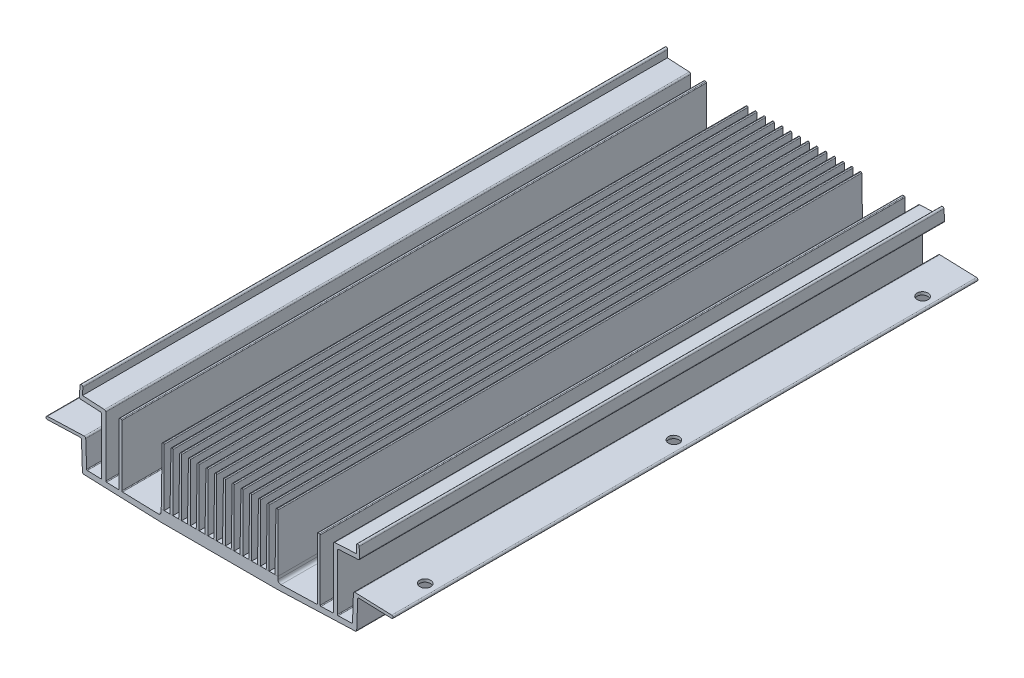
from build123d import *

# Parameters (mm, degrees)
BOSS_EXTRUDE1_DEPTH                               = 200.5
SKETCH3_W                                         = 1
SKETCH3_H                                         = 200.5
BOSS_EXTRUDE2_DEPTH                               = 19.75
BOSS_EXTRUDE2_TAPER                               = 0.5
FILLET5_R                                         = 0.3
LPATTERN1_COUNT                                   = 14
LPATTERN1_PITCH                                   = 3
FILLET5_OF_LPATTERN1_R                            = 0.3
FILLET1_R                                         = 1
FILLET2_R                                         = 0.5
FILLET4_R                                         = 0.25
CSK_FOR_6_FLAT_HEAD_SOCKET_CAP_SCREW_D            = 3.7973
CSK_FOR_6_FLAT_HEAD_SOCKET_CAP_SCREW_DEPTH        = 20
CSK_FOR_6_FLAT_HEAD_SOCKET_CAP_SCREW_CSINK_D      = 7.7978
CSK_FOR_6_FLAT_HEAD_SOCKET_CAP_SCREW_CSINK_ANGLE  = 82
CSK_FOR_6_FLAT_HEAD_SOCKET_CAP_SCREW_TIP          = 1.140824014
CSK_FOR_6_FLAT_HEAD_SOCKET_CAP_SCRE_2_D           = 3.7973
CSK_FOR_6_FLAT_HEAD_SOCKET_CAP_SCRE_2_DEPTH       = 20
CSK_FOR_6_FLAT_HEAD_SOCKET_CAP_SCRE_2_CSINK_D     = 7.7978
CSK_FOR_6_FLAT_HEAD_SOCKET_CAP_SCRE_2_CSINK_ANGLE = 82
CSK_FOR_6_FLAT_HEAD_SOCKET_CAP_SCRE_2_TIP         = 1.140824014


with BuildPart() as part:
    # Sketch1 → Boss-Extrude1 (new body)
    with BuildSketch(Plane.XY):
        with BuildLine():
            Line((-59.017449748, 11.987290212), (-45.898768022, 12.445404673))
            Line((-45.898768022, 12.445404673), (-45.560123885, 2.7479054))
            Line((-45.560123885, 2.7479054), (-40.4, 2.59691691))
            Line((-40.4, 2.59691691), (-40.4, 22.371380989))
            Line((-40.4, 22.371380989), (-48.063552949, 22.773010781))
            Line((-48.063552949, 22.773010781), (-47.854209124, 26.76752892))
            ThreePointArc((-47.854209124, 26.76752892), (-47.328726379, 27.240675709), (-46.85557959, 26.715192964))
            Line((-46.85557959, 26.715192964), (-46.989036278, 24.16868765))
            Line((-46.989036278, 24.16868765), (-39, 23.75))
            Line((-39, 23.75), (-39, 2.555952024))
            Line((-39, 2.555952024), (-34.5, 2.424279176))
            Line((-34.5, 2.424279176), (-34.5, 23.75))
            Line((-34.5, 23.75), (-33.5, 23.75))
            Line((-33.5, 23.75), (-33.5, 2.395018543))
            Line((-33.5, 2.395018543), (-20, 2))
            Line((-20, 2), (-20, 4))
            Line((-20, 4), (20, 4))
            Line((20, 4), (20, 2))
            Line((20, 2), (33.5, 2.395018543))
            Line((33.5, 2.395018543), (33.5, 23.75))
            Line((33.5, 23.75), (34.5, 23.75))
            Line((34.5, 23.75), (34.5, 2.424279176))
            Line((34.5, 2.424279176), (39, 2.555952024))
            Line((39, 2.555952024), (39, 23.75))
            Line((39, 23.75), (46.989036278, 24.16868765))
            Line((46.989036278, 24.16868765), (46.85557959, 26.715192964))
            ThreePointArc((46.85557959, 26.715192964), (47.328726379, 27.240675709), (47.854209124, 26.76752892))
            Line((47.854209124, 26.76752892), (48.063552949, 22.773010781))
            Line((48.063552949, 22.773010781), (40.4, 22.371380989))
            Line((40.4, 22.371380989), (40.4, 2.59691691))
            Line((40.4, 2.59691691), (45.560123885, 2.7479054))
            Line((45.560123885, 2.7479054), (45.898768022, 12.445404673))
            Line((45.898768022, 12.445404673), (59.017449748, 11.987290212))
            ThreePointArc((59.017449748, 11.987290212), (59.499695414, 11.470145051), (58.982550252, 10.987899385))
            Line((58.982550252, 10.987899385), (47.362954766, 11.393664601))
            Line((47.362954766, 11.393664601), (47, 1))
            Line((47, 1), (20, 0))
            Line((20, 0), (-20, 0))
            Line((-20, 0), (-47, 1))
            Line((-47, 1), (-47.362954766, 11.393664601))
            Line((-47.362954766, 11.393664601), (-58.982550252, 10.987899385))
            ThreePointArc((-58.982550252, 10.987899385), (-59.499695414, 11.470145051), (-59.017449748, 11.987290212))
        make_face()
    extrude(amount=BOSS_EXTRUDE1_DEPTH)

    # Sketch3 → Boss-Extrude2 (add)
    with BuildSketch(Plane(origin=(0, 4, 0), x_dir=(1, 0, 0), z_dir=(0, 1, 0))):
        with Locations((-19.5, -100.25)):
            Rectangle(SKETCH3_W, SKETCH3_H)
    boss_extrude2 = extrude(amount=BOSS_EXTRUDE2_DEPTH, taper=BOSS_EXTRUDE2_TAPER)

    # Fillet5
    fillet5_edges = [part.edges().sort_by_distance(p)[0] for p in [
        (-19.172355639, 23.75, 100.25),
        (-19.827644361, 23.75, 100.25),
    ]]
    fillet(fillet5_edges, radius=FILLET5_R)

    # LPattern1: Boss-Extrude2 ×14
    with Locations(*[(i * LPATTERN1_PITCH, 0, 0) for i in range(1, LPATTERN1_COUNT)]):
        add(boss_extrude2)

    # Fillet5 of LPattern1
    fillet5_of_lpattern1_edges = [part.edges().sort_by_distance(p)[0] for p in [
        (-16.172355639, 23.75, 100.25),
        (-16.827644361, 23.75, 100.25),
        (-13.172355639, 23.75, 100.25),
        (-13.827644361, 23.75, 100.25),
        (-10.172355639, 23.75, 100.25),
        (-10.827644361, 23.75, 100.25),
        (-7.172355639, 23.75, 100.25),
        (-7.827644361, 23.75, 100.25),
        (-4.172355639, 23.75, 100.25),
        (-4.827644361, 23.75, 100.25),
        (-1.172355639, 23.75, 100.25),
        (-1.827644361, 23.75, 100.25),
        (1.827644361, 23.75, 100.25),
        (1.172355639, 23.75, 100.25),
        (4.827644361, 23.75, 100.25),
        (4.172355639, 23.75, 100.25),
        (7.827644361, 23.75, 100.25),
        (7.172355639, 23.75, 100.25),
        (10.827644361, 23.75, 100.25),
        (10.172355639, 23.75, 100.25),
        (13.827644361, 23.75, 100.25),
        (13.172355639, 23.75, 100.25),
        (16.827644361, 23.75, 100.25),
        (16.172355639, 23.75, 100.25),
        (19.827644361, 23.75, 100.25),
        (19.172355639, 23.75, 100.25),
    ]]
    fillet(fillet5_of_lpattern1_edges, radius=FILLET5_OF_LPATTERN1_R)

    # Fillet1
    fillet1_edges = [part.edges().sort_by_distance(p)[0] for p in [
        (-20, 2, 100.25),
        (20, 2, 100.25),
    ]]
    fillet(fillet1_edges, radius=FILLET1_R)

    # Fillet2
    fillet2_edges = [part.edges().sort_by_distance(p)[0] for p in [
        (-45.898768022, 12.445404673, 100.25),
        (-40.4, 22.371380989, 100.25),
        (-48.063552949, 22.773010781, 100.25),
        (-39, 23.75, 100.25),
        (39, 23.75, 100.25),
        (48.063552949, 22.773010781, 100.25),
        (40.4, 22.371380989, 100.25),
        (45.898768022, 12.445404673, 100.25),
        (47.362954766, 11.393664601, 100.25),
        (47, 1, 100.25),
        (-47, 1, 100.25),
        (-47.362954766, 11.393664601, 100.25),
    ]]
    fillet(fillet2_edges, radius=FILLET2_R)

    # Fillet4
    fillet4_edges = [part.edges().sort_by_distance(p)[0] for p in [
        (-45.560123885, 2.7479054, 100.25),
        (-40.4, 2.59691691, 100.25),
        (-39, 2.555952024, 100.25),
        (-34.5, 2.424279176, 100.25),
        (-34.5, 23.75, 100.25),
        (-33.5, 23.75, 100.25),
        (-33.5, 2.395018543, 100.25),
        (33.5, 2.395018543, 100.25),
        (33.5, 23.75, 100.25),
        (34.5, 23.75, 100.25),
        (34.5, 2.424279176, 100.25),
        (39, 2.555952024, 100.25),
        (40.4, 2.59691691, 100.25),
        (45.560123885, 2.7479054, 100.25),
    ]]
    fillet(fillet4_edges, radius=FILLET4_R)

    # CSK for _6 Flat Head Socket Cap Screw
    with Locations(Plane(origin=(-59.5, -7, 134.24973), x_dir=(0, 0, 1), z_dir=(0, -1, 0))):
        with Locations((-119.24973, 115), (-33.99973, 115), (51.25027, 115), (51.25027, -115), (-33.99973, -115), (-119.24973, -115)):
            CounterSinkHole(CSK_FOR_6_FLAT_HEAD_SOCKET_CAP_SCREW_D / 2, CSK_FOR_6_FLAT_HEAD_SOCKET_CAP_SCREW_CSINK_D / 2, depth=CSK_FOR_6_FLAT_HEAD_SOCKET_CAP_SCREW_DEPTH, counter_sink_angle=CSK_FOR_6_FLAT_HEAD_SOCKET_CAP_SCREW_CSINK_ANGLE)
            with Locations((0, 0, -(CSK_FOR_6_FLAT_HEAD_SOCKET_CAP_SCREW_DEPTH + CSK_FOR_6_FLAT_HEAD_SOCKET_CAP_SCREW_TIP / 2))):  # 118° drill point
                Cone(0, CSK_FOR_6_FLAT_HEAD_SOCKET_CAP_SCREW_D / 2, CSK_FOR_6_FLAT_HEAD_SOCKET_CAP_SCREW_TIP, mode=Mode.SUBTRACT)

    # CSK for _6 Flat Head Socket Cap Scre 2
    with Locations(Plane(origin=(59.5, -7, 134.24973), x_dir=(0, 0, 1), z_dir=(0, -1, 0))):
        with Locations((-119.24973, 115), (-33.99973, 115), (51.25027, 115), (51.25027, -115), (-33.99973, -115), (-119.24973, -115)):
            CounterSinkHole(CSK_FOR_6_FLAT_HEAD_SOCKET_CAP_SCRE_2_D / 2, CSK_FOR_6_FLAT_HEAD_SOCKET_CAP_SCRE_2_CSINK_D / 2, depth=CSK_FOR_6_FLAT_HEAD_SOCKET_CAP_SCRE_2_DEPTH, counter_sink_angle=CSK_FOR_6_FLAT_HEAD_SOCKET_CAP_SCRE_2_CSINK_ANGLE)
            with Locations((0, 0, -(CSK_FOR_6_FLAT_HEAD_SOCKET_CAP_SCRE_2_DEPTH + CSK_FOR_6_FLAT_HEAD_SOCKET_CAP_SCRE_2_TIP / 2))):  # 118° drill point
                Cone(0, CSK_FOR_6_FLAT_HEAD_SOCKET_CAP_SCRE_2_D / 2, CSK_FOR_6_FLAT_HEAD_SOCKET_CAP_SCRE_2_TIP, mode=Mode.SUBTRACT)


solid = part.part
